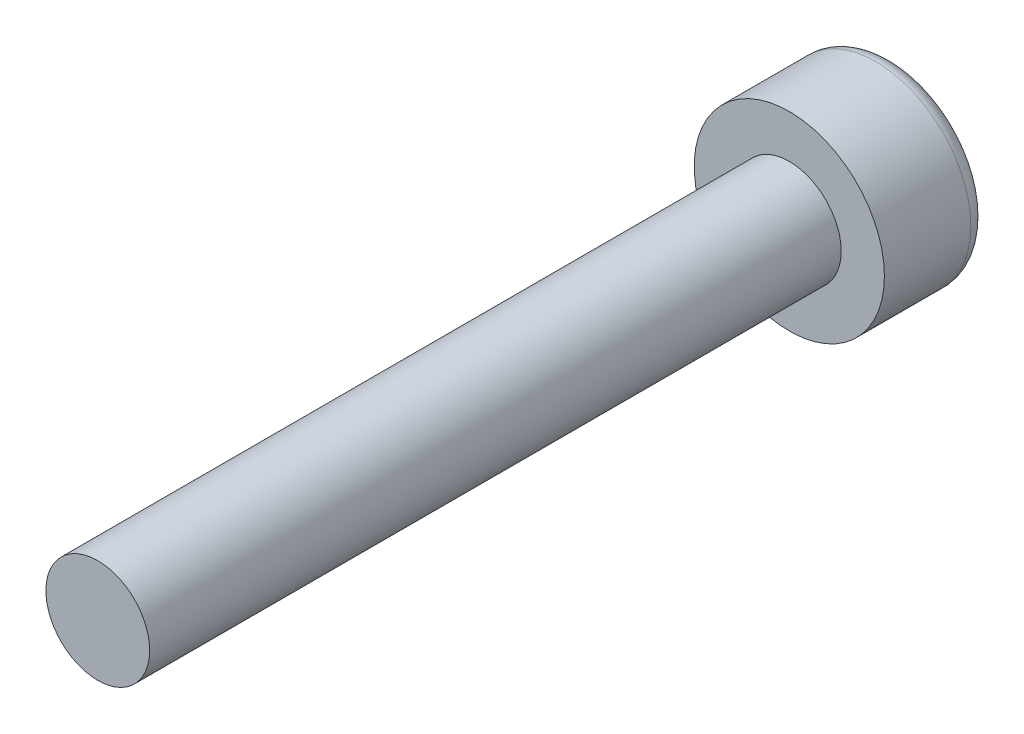
from build123d import *

# Parameters (mm, degrees)
SKETCH_2_R      = 2.75
EXTRUDE_1_DEPTH = 3
SKETCH_3_R      = 1.5
EXTRUDE_2_DEPTH = 20
FILLET_1_R      = 0.5


with BuildPart() as part:
    # ｽｹｯﾁ2 → ﾎﾞｽ - 押し出し1 (new body)
    with BuildSketch(Plane.XY):
        Circle(SKETCH_2_R)
    extrude(amount=EXTRUDE_1_DEPTH)

    # ｽｹｯﾁ3 → ﾎﾞｽ - 押し出し2 (add)
    with BuildSketch(Plane.XY.offset(3)):
        Circle(SKETCH_3_R)
    extrude(amount=EXTRUDE_2_DEPTH)

    # ﾌｨﾚｯﾄ1
    fillet_1_edges = [part.edges().sort_by_distance(p)[0] for p in [
        (-2.75, 0, 0),
    ]]
    fillet(fillet_1_edges, radius=FILLET_1_R)


solid = part.part
